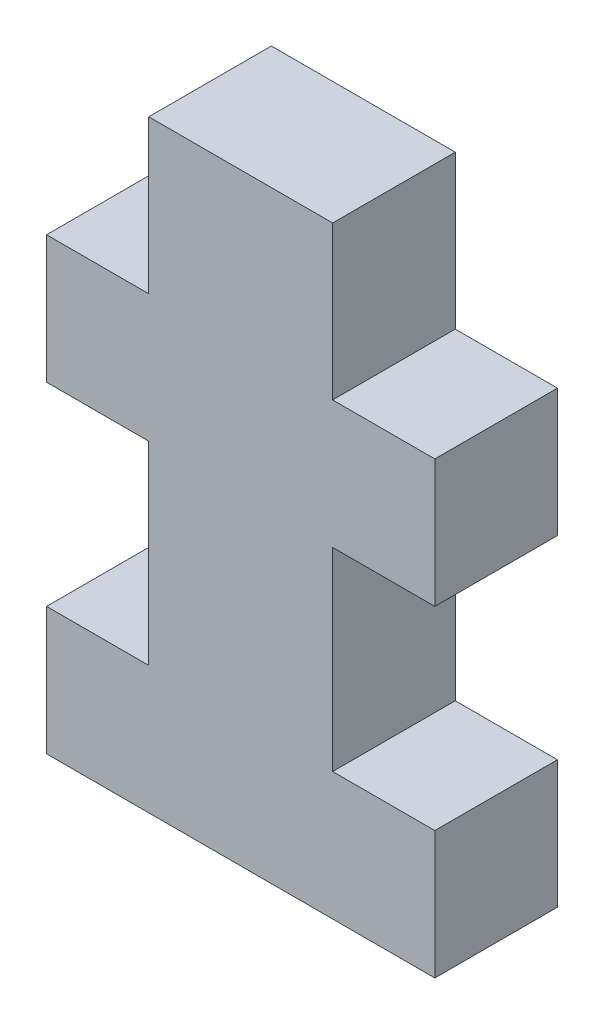
from build123d import *

# Parameters (mm, degrees)
BOSS_EXTRUDE1_DEPTH = 3.048


with BuildPart() as part:
    # Sketch1 → Boss-Extrude1 (new, symmetric)
    with BuildSketch(Plane.XY):
        Polygon((4.572, 61.976), (4.572, 71.628), (9.652, 71.628), (9.652, 77.978), (4.572, 77.978), (4.572, 85.598), (-4.572, 85.598), (-4.572, 77.978), (-9.652, 77.978), (-9.652, 71.628), (-4.572, 71.628), (-4.572, 61.976), (-9.652, 61.976), (-9.652, 55.626), (9.652, 55.626), (9.652, 61.976), align=None)
    extrude(amount=BOSS_EXTRUDE1_DEPTH, both=True)


solid = part.part
